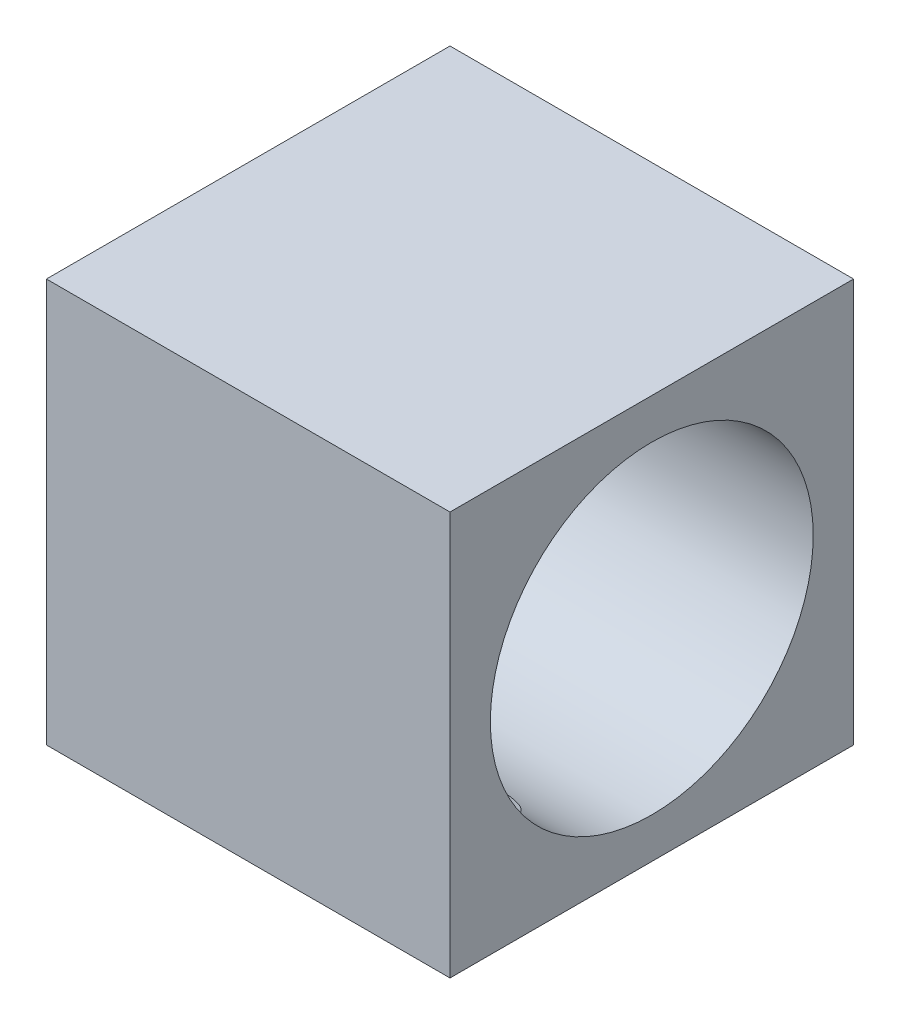
from build123d import *

# Parameters (mm, degrees)
SKETCH1_W               = 20
SKETCH1_H               = 20
BOSS_EXTRUDE1_DEPTH     = 20
SKETCH2_R               = 8
CUT_EXTRUDE1_DEPTH      = 20
CUT_EXTRUDE1_DEPTH_BACK = 20
SKETCH3_R               = 2.5
CUT_EXTRUDE2_DEPTH      = 5


with BuildPart() as part:
    # Sketch1 → Boss-Extrude1 (new body)
    with BuildSketch(Plane(origin=(0, 0, 0), x_dir=(1, 0, 0), z_dir=(0, 1, 0))):
        Rectangle(SKETCH1_W, SKETCH1_H)
    extrude(amount=BOSS_EXTRUDE1_DEPTH)

    # Sketch2 → Cut-Extrude1 (cut, two sides)
    with BuildSketch(Plane(origin=(0, 0, 0), x_dir=(0, 0, -1), z_dir=(1, 0, 0))) as cut_extrude1_sk:
        with Locations((0, 10)):
            Circle(SKETCH2_R)
    extrude(amount=CUT_EXTRUDE1_DEPTH, mode=Mode.SUBTRACT)
    extrude(cut_extrude1_sk.sketch, amount=-CUT_EXTRUDE1_DEPTH_BACK, mode=Mode.SUBTRACT)

    # Sketch3 → Cut-Extrude2 (cut)
    with BuildSketch(Plane(origin=(0, 0, 0), x_dir=(-1, 0, 0), z_dir=(0, -1, 0))):
        with Locations((-6, -6)):
            Circle(SKETCH3_R)
        with Locations((6, 6)):
            Circle(SKETCH3_R)
    extrude(amount=-CUT_EXTRUDE2_DEPTH, mode=Mode.SUBTRACT)


solid = part.part
